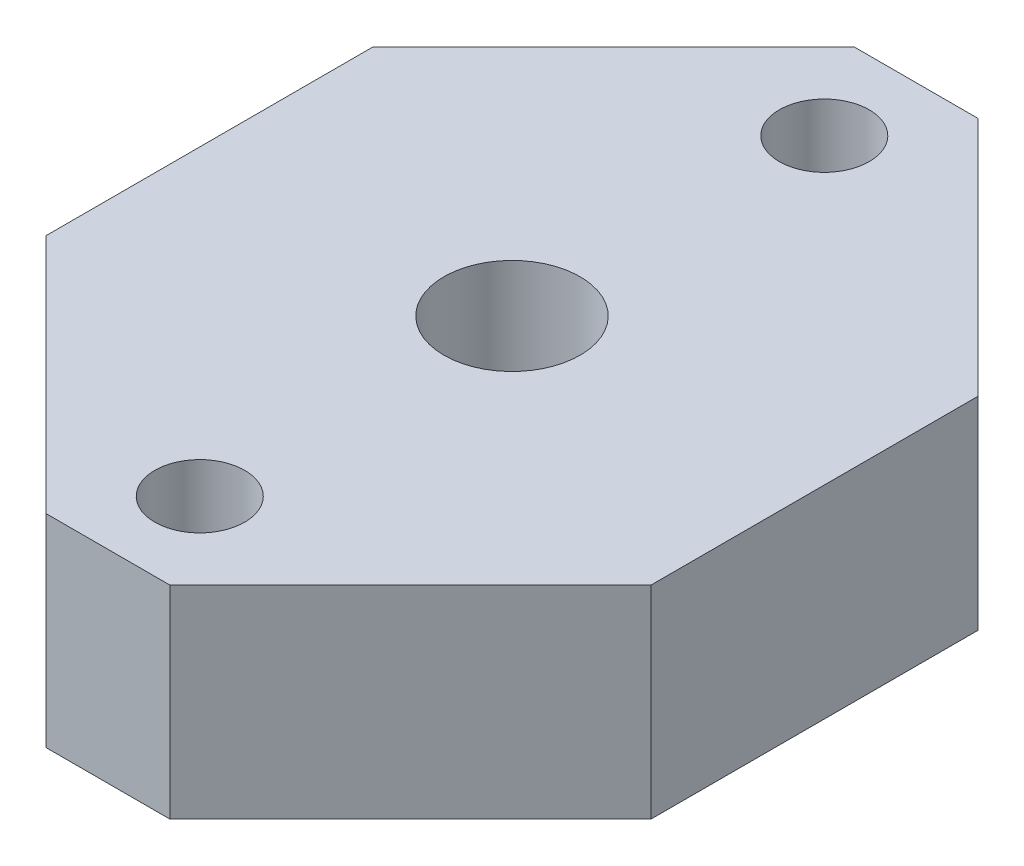
from build123d import *

# Parameters (mm, degrees)
SKETCH1_W           = 35.56
SKETCH1_H           = 47.498
SKETCH1_R           = 2.6416
SKETCH1_R_2         = 4
BOSS_EXTRUDE1_DEPTH = 11.9126
CUT_EXTRUDE1_DEPTH  = 12.9126


with BuildPart() as part:
    # Sketch1 → Boss-Extrude1 (new body)
    with BuildSketch(Plane(origin=(0, 0, 0), x_dir=(1, 0, 0), z_dir=(0, 1, 0))):
        with Locations((17.78, 23.749)):
            Rectangle(SKETCH1_W, SKETCH1_H)
        with Locations((17.78, 42.1005)):
            Circle(SKETCH1_R, mode=Mode.SUBTRACT)
        with Locations((17.78, 5.3975)):
            Circle(SKETCH1_R, mode=Mode.SUBTRACT)
        with Locations((17.78, 23.749)):
            Circle(SKETCH1_R_2, mode=Mode.SUBTRACT)
    extrude(amount=BOSS_EXTRUDE1_DEPTH)

    # Sketch2 → Cut-Extrude1 (cut, through all)
    with BuildSketch(Plane(origin=(0, 11.9126, 0), x_dir=(1, 0, 0), z_dir=(0, 1, 0))):
        Polygon((14.142135624, 0), (0, 14.142135624), (0, 0), align=None)
        Polygon((21.417864376, 0), (35.56, 14.142135624), (35.56, 0), align=None)
        Polygon((21.417864376, 47.498), (35.56, 47.498), (35.56, 33.355864376), align=None)
        Polygon((14.142135624, 47.498), (0, 33.355864376), (0, 47.498), align=None)
    extrude(amount=-CUT_EXTRUDE1_DEPTH, mode=Mode.SUBTRACT)


solid = part.part
